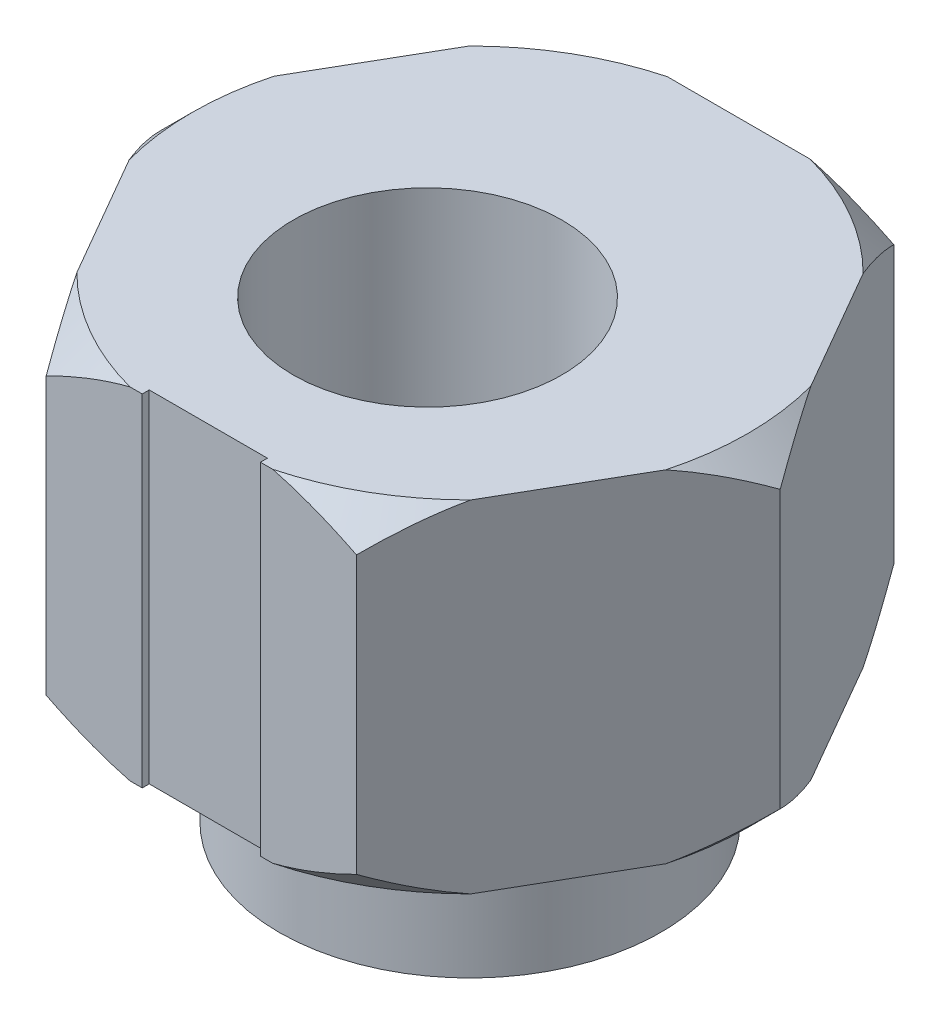
from build123d import *

# Parameters (mm, degrees)
BOSS_EXTRUDE1_DEPTH = 6.35
SKETCH3_R           = 3.555
BOSS_EXTRUDE3_DEPTH = 2.5
SKETCH4_R           = 2.5
CUT_EXTRUDE1_DEPTH  = 9.85
SKETCH5_W           = 2.2
SKETCH5_H           = 0.13
CUT_EXTRUDE2_DEPTH  = 7.35


with BuildPart() as part:
    # Sketch1 → Boss-Extrude1 (new body)
    with BuildSketch(Plane(origin=(0, 0, 0), x_dir=(1, 0, 0), z_dir=(0, 1, 0))):
        Polygon((5.773502692, 0), (2.886751346, 5), (-2.886751346, 5), (-5.773502692, 0), (-2.886751346, -5), (2.886751346, -5), align=None)
    extrude(amount=BOSS_EXTRUDE1_DEPTH)

    # Sketch3 → Boss-Extrude3 (add)
    with BuildSketch(Plane.XZ):
        Circle(SKETCH3_R)
    extrude(amount=BOSS_EXTRUDE3_DEPTH)

    # Sketch4 → Cut-Extrude1 (cut, through all)
    with BuildSketch(Plane(origin=(0, 6.35, 0), x_dir=(1, 0, 0), z_dir=(0, 1, 0))):
        with Locations((0, -0.79)):
            Circle(SKETCH4_R)
    extrude(amount=-CUT_EXTRUDE1_DEPTH, mode=Mode.SUBTRACT)

    # Sketch5 → Cut-Extrude2 (cut, through all)
    with BuildSketch(Plane(origin=(0, 0, 0), x_dir=(-1, 0, 0), z_dir=(0, -1, 0))):
        with Locations((0, -4.935)):
            Rectangle(SKETCH5_W, SKETCH5_H)
    extrude(amount=-CUT_EXTRUDE2_DEPTH, mode=Mode.SUBTRACT)

    # Sketch6 → Cut-Revolve1 (revolve, cut)
    with BuildSketch(Plane.XY):
        Polygon((5.173502692, 6.35), (5.773502692, 6.35), (5.773502692, 5.75), align=None)
        Polygon((5.773502692, 0.6), (5.173502692, 0), (5.773502692, 0), align=None)
    revolve(axis=Axis((0, 0, 0), (0, 1, 0)), mode=Mode.SUBTRACT)


solid = part.part
